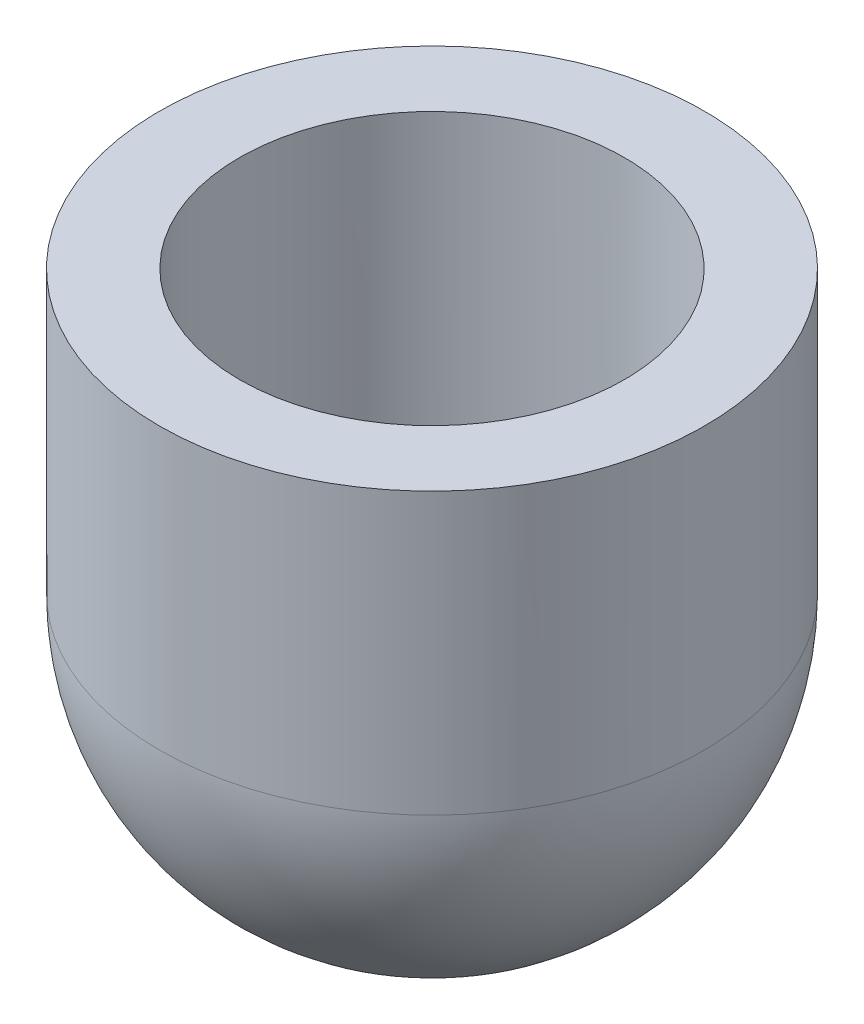
from build123d import *


with BuildPart() as part:
    # Sketch1 → Revolve1 (revolve)
    with BuildSketch(Plane(origin=(0, 0, 0), x_dir=(0, 0, -1), z_dir=(1, 0, 0))):
        with BuildLine():
            Line((8.636, 0), (6.096, 0))
            Line((6.096, 0), (6.096, -8.89))
            ThreePointArc((6.096, -8.89), (4.310522938, -13.200522938), (0, -14.986))
            Line((0, -14.986), (0, -17.526))
            ThreePointArc((0, -17.526), (6.106574162, -14.996574162), (8.636, -8.89))
            Line((8.636, -8.89), (8.636, 0))
        make_face()
    revolve(axis=Axis((0, 26.376898639, 0), (0, -1, 0)))


solid = part.part
